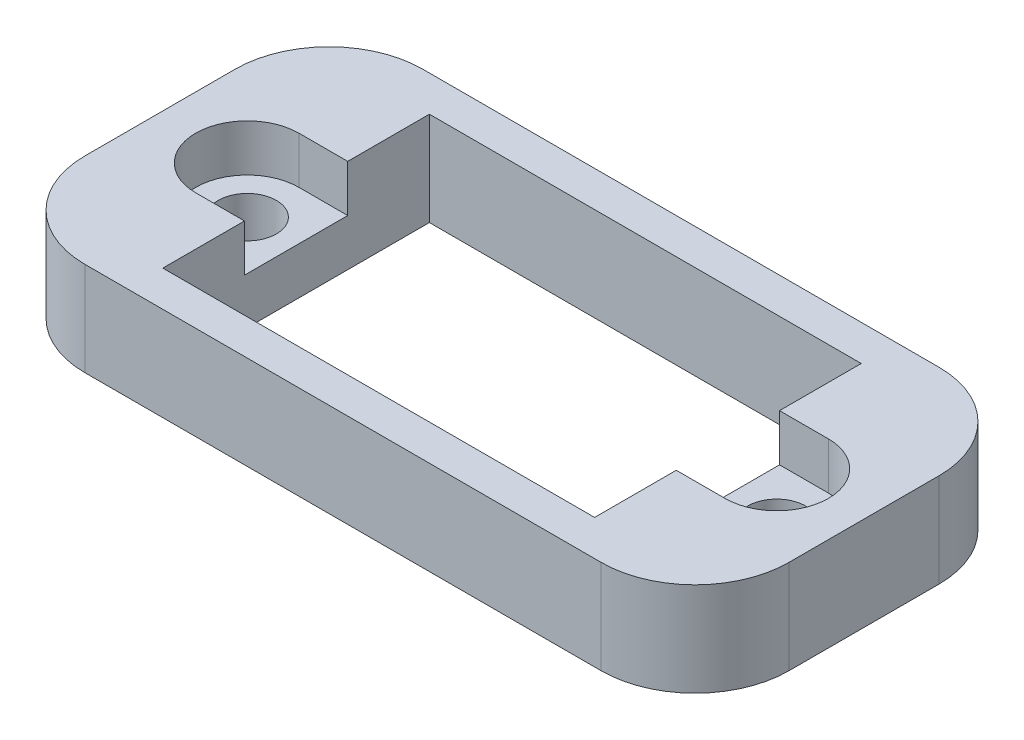
from build123d import *

# Parameters (mm, degrees)
SKETCH1_W           = 37.5
SKETCH1_H           = 18
SKETCH1_R           = 1.55
SKETCH1_W_2         = 23
SKETCH1_H_2         = 14.2
BOSS_EXTRUDE1_DEPTH = 5
SKETCH2_R           = 1.55
CUT_EXTRUDE1_DEPTH  = 2.5
FILLET1_R           = 5


with BuildPart() as part:
    # Sketch1 → Boss-Extrude1 (new body)
    with BuildSketch(Plane(origin=(0, 0, 0), x_dir=(1, 0, 0), z_dir=(0, 1, 0))):
        Rectangle(SKETCH1_W, SKETCH1_H)
        with Locations((-14.1, 0)):
            Circle(SKETCH1_R, mode=Mode.SUBTRACT)
        with Locations((14.1, 0)):
            Circle(SKETCH1_R, mode=Mode.SUBTRACT)
        Rectangle(SKETCH1_W_2, SKETCH1_H_2, mode=Mode.SUBTRACT)
    extrude(amount=BOSS_EXTRUDE1_DEPTH)

    # Sketch2 → Cut-Extrude1 (cut)
    with BuildSketch(Plane(origin=(0, 5, 0), x_dir=(1, 0, 0), z_dir=(0, 1, 0))):
        with BuildLine():
            ThreePointArc((11.5, 0.895823643), (12.503286973, 2.238974656), (14.1, 2.75))
            Line((14.1, 2.75), (11.5, 2.75))
            Line((11.5, 2.75), (11.5, 0.895823643))
        make_face()
        with BuildLine():
            Line((11.5, -2.75), (14.1, -2.75))
            ThreePointArc((14.1, -2.75), (12.503286973, -2.238974656), (11.5, -0.895823643))
            Line((11.5, -0.895823643), (11.5, -2.75))
        make_face()
        with BuildLine():
            ThreePointArc((16.85, 0), (16.044543648, 1.944543648), (14.1, 2.75))
            ThreePointArc((14.1, 2.75), (12.503286973, 2.238974656), (11.5, 0.895823643))
            Line((11.5, 0.895823643), (11.5, -0.895823643))
            ThreePointArc((11.5, -0.895823643), (12.503286973, -2.238974656), (14.1, -2.75))
            ThreePointArc((14.1, -2.75), (16.044543648, -1.944543648), (16.85, 0))
        make_face()
        with Locations((14.1, 0)):
            Circle(SKETCH2_R, mode=Mode.SUBTRACT)
        with BuildLine():
            ThreePointArc((-11.5, -0.895823643), (-12.503286973, -2.238974656), (-14.1, -2.75))
            Line((-14.1, -2.75), (-11.5, -2.75))
            Line((-11.5, -2.75), (-11.5, -0.895823643))
        make_face()
        with BuildLine():
            Line((-11.5, 2.75), (-14.1, 2.75))
            ThreePointArc((-14.1, 2.75), (-12.503286973, 2.238974656), (-11.5, 0.895823643))
            Line((-11.5, 0.895823643), (-11.5, 2.75))
        make_face()
        with BuildLine():
            ThreePointArc((-11.5, 0.895823643), (-12.503286973, 2.238974656), (-14.1, 2.75))
            ThreePointArc((-14.1, 2.75), (-16.85, 0), (-14.1, -2.75))
            ThreePointArc((-14.1, -2.75), (-12.503286973, -2.238974656), (-11.5, -0.895823643))
            Line((-11.5, -0.895823643), (-11.5, 0.895823643))
        make_face()
        with Locations((-14.1, 0)):
            Circle(SKETCH2_R, mode=Mode.SUBTRACT)
    extrude(amount=-CUT_EXTRUDE1_DEPTH, mode=Mode.SUBTRACT)

    # Fillet1
    fillet1_edges = [part.edges().sort_by_distance(p)[0] for p in [
        (18.75, 2.5, 9),
        (-18.75, 2.5, 9),
        (-18.75, 2.5, -9),
        (18.75, 2.5, -9),
    ]]
    fillet(fillet1_edges, radius=FILLET1_R)


solid = part.part
